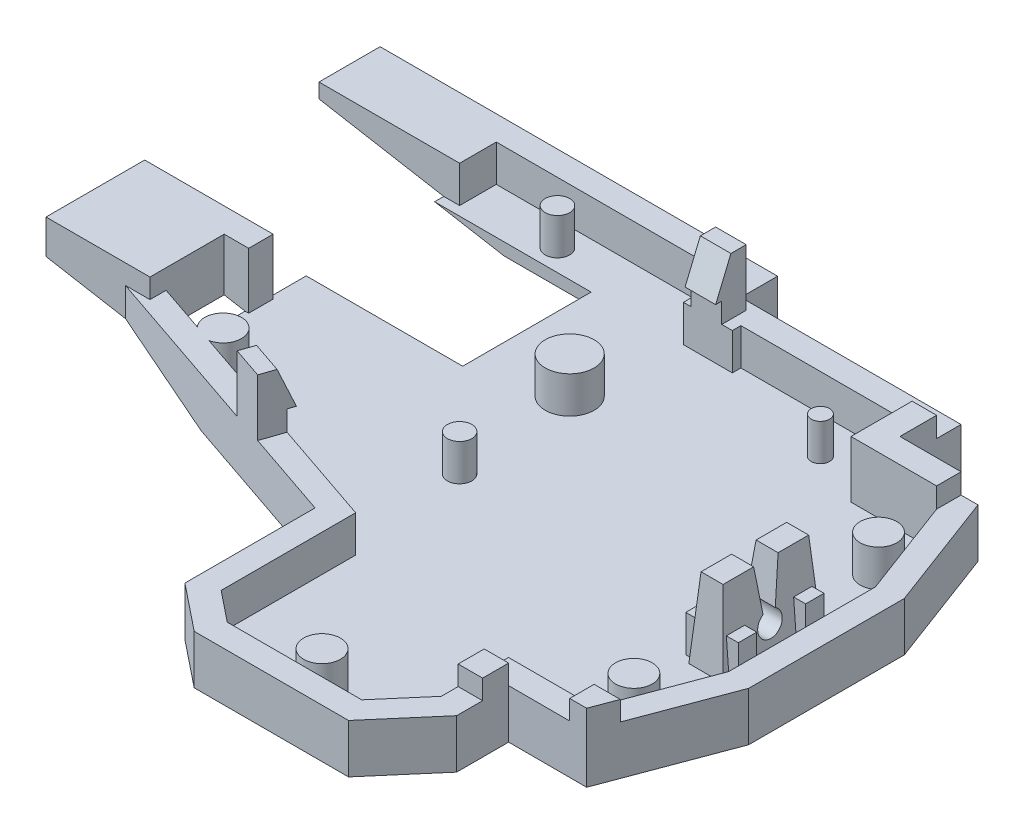
from build123d import *

# Parameters (mm, degrees)
SKETCH13_W           = 50
SKETCH13_H           = 45
BOSS_EXTRUDE4_DEPTH  = 1.6
SKETCH14_W           = 10
SKETCH14_H           = 8
CUT_EXTRUDE6_DEPTH   = 2.6
SKETCH15_W           = 18
SKETCH15_H           = 3
CUT_EXTRUDE7_DEPTH   = 2.6
SKETCH16_W           = 4
SKETCH16_H           = 0.7
CUT_EXTRUDE8_DEPTH   = 2.6
CUT_EXTRUDE9_DEPTH   = 2.6
SKETCH18_W           = 21.109590793
SKETCH18_H           = 22.840524871
CUT_EXTRUDE10_DEPTH  = 2.6
CUT_EXTRUDE11_DEPTH  = 2.6
SKETCH22_W           = 2
SKETCH22_H           = 3
CUT_EXTRUDE12_DEPTH  = 2.6
CUT_EXTRUDE13_DEPTH  = 2.6
CUT_EXTRUDE14_DEPTH  = 2.6
SKETCH25_W           = 2.8
SKETCH25_H           = 8
CUT_EXTRUDE15_DEPTH  = 2.6
BOSS_EXTRUDE6_DEPTH  = 6
SKETCH30_W           = 2.8
SKETCH30_H           = 8
BOSS_EXTRUDE7_DEPTH  = 3.5
CUT_EXTRUDE16_DEPTH  = 4.6
SKETCH32_W           = 2.8
SKETCH32_H           = 8
BOSS_EXTRUDE8_DEPTH  = 4.6
CUT_EXTRUDE18_DEPTH  = 4.6
SKETCH37_R           = 1
CUT_EXTRUDE19_DEPTH  = 4.6
CUT_EXTRUDE20_DEPTH  = 4.6
CUT_EXTRUDE21_START  = 6
CUT_EXTRUDE21_DEPTH  = 20.059798
BOSS_EXTRUDE9_DEPTH  = 4.6
SKETCH44_W           = 4.3
SKETCH44_H           = 1.5
BOSS_EXTRUDE11_DEPTH = 3
SKETCH45_R           = 1.5
SKETCH45_R_2         = 1
SKETCH45_R_3         = 1.999622229
SKETCH45_R_4         = 1.503341979
SKETCH45_R_5         = 0.75
BOSS_EXTRUDE12_DEPTH = 3
SKETCH46_W           = 2.5
SKETCH46_H           = 2
SKETCH46_W_2         = 2
BOSS_EXTRUDE13_DEPTH = 1.65
SKETCH47_W           = 3
SKETCH47_H           = 3
BOSS_EXTRUDE14_DEPTH = 3
SKETCH48_W           = 2
SKETCH48_H           = 16.336241737
CUT_EXTRUDE22_DEPTH  = 3
SKETCH49_W           = 21.336241737
SKETCH49_H           = 3
BOSS_EXTRUDE15_DEPTH = 13
SKETCH50_W           = 67
SKETCH50_H           = 49
BOSS_EXTRUDE16_DEPTH = 3
SKETCH51_W           = 5
SKETCH51_H           = 11
BOSS_EXTRUDE17_DEPTH = 15.6
CUT_EXTRUDE23_DEPTH  = 1.65
SKETCH53_W           = 2
SKETCH53_H           = 2.129349353
BOSS_EXTRUDE18_DEPTH = 1.6
SKETCH55_W           = 2.5
SKETCH55_H           = 2.5
BOSS_EXTRUDE20_DEPTH = 3
CUT_EXTRUDE24_DEPTH  = 3
SKETCH58_W           = 20
SKETCH58_H           = 10.5
SKETCH58_W_2         = 2
SKETCH58_H_2         = 2
CUT_EXTRUDE29_DEPTH  = 1
BOSS_EXTRUDE21_DEPTH = 3
BOSS_EXTRUDE22_REACH = 41.731
SKETCH61_W           = 2.5
SKETCH61_H           = 1.65
CUT_EXTRUDE30_DEPTH  = 3
CUT_EXTRUDE31_REACH  = 43.731
SKETCH64_W           = 2.551500858
SKETCH64_H           = 4.310788114
CUT_EXTRUDE32_DEPTH  = 4.65
SKETCH65_W           = 2
SKETCH65_H           = 2
BOSS_EXTRUDE23_DEPTH = 4
SKETCH66_W           = 2
SKETCH66_H           = 2
BOSS_EXTRUDE24_DEPTH = 1.6
SKETCH67_W           = 2.5
SKETCH67_H           = 2
BOSS_EXTRUDE25_DEPTH = 3
CUT_EXTRUDE33_DEPTH  = 3
BOSS_EXTRUDE26_DEPTH = 1.65
SKETCH70_W           = 5.055009343
SKETCH70_H           = 5.560438358
CUT_EXTRUDE34_DEPTH  = 3
BOSS_EXTRUDE27_DEPTH = 3
CUT_EXTRUDE35_DEPTH  = 3
BOSS_EXTRUDE28_REACH = 39.863
CUT_EXTRUDE36_DEPTH  = 3
FILLET8_R            = 1
SKETCH76_W           = 7
SKETCH76_H           = 14.5
BOSS_EXTRUDE29_DEPTH = 14.5
BOSS_EXTRUDE30_DEPTH = 2
CUT_EXTRUDE37_DEPTH  = 2
BOSS_EXTRUDE31_DEPTH = 2.684479
SKETCH85_W           = 30.566158209
SKETCH85_H           = 1.725230041
BOSS_EXTRUDE33_DEPTH = 3
BOSS_EXTRUDE34_DEPTH = 3
BOSS_EXTRUDE35_DEPTH = 3
SKETCH88_W           = 27.09375
SKETCH88_H           = 14.5
BOSS_EXTRUDE36_DEPTH = 1.6
SKETCH90_W           = 7
SKETCH90_H           = 14.5
BOSS_EXTRUDE37_DEPTH = 1.6
SKETCH93_W           = 5
SKETCH93_H           = 11
BOSS_EXTRUDE38_DEPTH = 0.5
SKETCH94_W           = 8.605758832
SKETCH94_H           = 2
BOSS_EXTRUDE39_DEPTH = 15.6
SKETCH96_W           = 8.605758832
SKETCH96_H           = 2
BOSS_EXTRUDE40_DEPTH = 0.5
SKETCH97_W           = 2
SKETCH97_H           = 49
BOSS_EXTRUDE41_DEPTH = 19.1
SKETCH98_W           = 69
SKETCH98_H           = 2
BOSS_EXTRUDE42_DEPTH = 19.1
SKETCH99_W           = 2
SKETCH99_H           = 3
BOSS_EXTRUDE43_DEPTH = 2.087376
SKETCH100_W          = 2
SKETCH100_H          = 51
BOSS_EXTRUDE45_DEPTH = 19.1
SKETCH101_W          = 71
SKETCH101_H          = 2
BOSS_EXTRUDE46_DEPTH = 19.1
BOSS_EXTRUDE47_DEPTH = 16.1
BOSS_EXTRUDE48_DEPTH = 16.1
FILLET9_R            = 2
SKETCH105_OUTSIDE_W  = 91.128
SKETCH105_OUTSIDE_H  = 73.128
CUT_EXTRUDE38_DEPTH  = 3
SKETCH106_W          = 77.0560479
SKETCH106_H          = 58.523580684
CUT_EXTRUDE39_DEPTH  = 20.1
SKETCH107_W          = 13.37564089
SKETCH107_H          = 6.179627402
CUT_EXTRUDE40_DEPTH  = 11.5
CUT_EXTRUDE41_DEPTH  = 4
SKETCH114_W          = 66.336817547
SKETCH114_H          = 51.668552302
CUT_EXTRUDE42_DEPTH  = 2
BOSS_EXTRUDE49_DEPTH = 6.5
SKETCH116_W          = 0.628599621
SKETCH116_H          = 10.5
CUT_EXTRUDE43_DEPTH  = 6.5
SKETCH117_W          = 8.5
SKETCH117_H          = 8.070282703
BOSS_EXTRUDE50_DEPTH = 1.6
SKETCH122_W          = 65.07142159
SKETCH122_H          = 113.694314663
CUT_EXTRUDE44_DEPTH  = 3.757461708


with BuildPart() as part:
    # Sketch13 → Boss-Extrude4 (new body)
    with BuildSketch(Plane(origin=(0, 0, 0), x_dir=(1, 0, 0), z_dir=(0, 1, 0))):
        with Locations((25, -22.5)):
            Rectangle(SKETCH13_W, SKETCH13_H)
    extrude(amount=BOSS_EXTRUDE4_DEPTH)

    # Sketch14 → Cut-Extrude6 (cut, through all)
    with BuildSketch(Plane(origin=(0, 1.6, 0), x_dir=(1, 0, 0), z_dir=(0, 1, 0))):
        with Locations((45, -4)):
            Rectangle(SKETCH14_W, SKETCH14_H)
    extrude(amount=-CUT_EXTRUDE6_DEPTH, mode=Mode.SUBTRACT)

    # Sketch15 → Cut-Extrude7 (cut, through all)
    with BuildSketch(Plane(origin=(0, 1.6, 0), x_dir=(1, 0, 0), z_dir=(0, 1, 0))):
        with Locations((31, -1.5)):
            Rectangle(SKETCH15_W, SKETCH15_H)
    extrude(amount=-CUT_EXTRUDE7_DEPTH, mode=Mode.SUBTRACT)

    # Sketch16 → Cut-Extrude8 (cut, through all)
    with BuildSketch(Plane(origin=(0, 1.6, 0), x_dir=(1, 0, 0), z_dir=(0, 1, 0))):
        with Locations((24, -3.35)):
            Rectangle(SKETCH16_W, SKETCH16_H)
    extrude(amount=-CUT_EXTRUDE8_DEPTH, mode=Mode.SUBTRACT)

    # Sketch17 → Cut-Extrude9 (cut, through all)
    with BuildSketch(Plane(origin=(0, 1.6, 0), x_dir=(1, 0, 0), z_dir=(0, 1, 0))):
        Polygon((47, -8), (50, -16), (65.881056194, -16), (65.881056194, 17.957346821), (47, 17.957346821), align=None)
    extrude(amount=-CUT_EXTRUDE9_DEPTH, mode=Mode.SUBTRACT)

    # Sketch18 → Cut-Extrude10 (cut, through all)
    with BuildSketch(Plane(origin=(0, 1.6, 0), x_dir=(1, 0, 0), z_dir=(0, 1, 0))):
        with Locations((50.554795396, -47.420262436)):
            Rectangle(SKETCH18_W, SKETCH18_H)
    extrude(amount=-CUT_EXTRUDE10_DEPTH, mode=Mode.SUBTRACT)

    # Sketch21 → Cut-Extrude11 (cut, through all)
    with BuildSketch(Plane(origin=(0, 1.6, 0), x_dir=(1, 0, 0), z_dir=(0, 1, 0))):
        Polygon((50, -28), (47, -36), (47, -49.297594069), (75.196774358, -49.297594069), (75.196774358, -28), align=None)
    extrude(amount=-CUT_EXTRUDE11_DEPTH, mode=Mode.SUBTRACT)

    # Sketch22 → Cut-Extrude12 (cut, through all)
    with BuildSketch(Plane(origin=(0, 1.6, 0), x_dir=(1, 0, 0), z_dir=(0, 1, 0))):
        with Locations((1, -20.836241737)):
            Rectangle(SKETCH22_W, SKETCH22_H)
    extrude(amount=-CUT_EXTRUDE12_DEPTH, mode=Mode.SUBTRACT)

    # Sketch23 → Cut-Extrude13 (cut, through all)
    with BuildSketch(Plane(origin=(0, 1.6, 0), x_dir=(1, 0, 0), z_dir=(0, 1, 0))):
        Polygon((23.5, -45), (23.5, -32), (0, -26.336241737), (-30.2261683, -26.336241737), (-30.2261683, -63.188280898), (23.5, -63.188280898), align=None)
    extrude(amount=-CUT_EXTRUDE13_DEPTH, mode=Mode.SUBTRACT)

    # Sketch24 → Cut-Extrude14 (cut, through all)
    with BuildSketch(Plane(origin=(0, 1.6, 0), x_dir=(1, 0, 0), z_dir=(0, 1, 0))):
        Polygon((23.5, -43), (7.491129632, -43), (7.491129632, -69.550234766), (44.754002286, -69.550234766), (44.754002286, -41.5), (40, -41.5), (37, -45), (26, -45), align=None)
    extrude(amount=-CUT_EXTRUDE14_DEPTH, mode=Mode.SUBTRACT)

    # Sketch25 → Cut-Extrude15 (cut, through all)
    with BuildSketch(Plane(origin=(0, 1.6, 0), x_dir=(1, 0, 0), z_dir=(0, 1, 0))):
        with Locations((46.200745069, -22.059797812)):
            Rectangle(SKETCH25_W, SKETCH25_H)
    extrude(amount=-CUT_EXTRUDE15_DEPTH, mode=Mode.SUBTRACT)

    # Sketch28 → Boss-Extrude6 (add)
    with BuildSketch(Plane.XZ):
        Polygon((42, 38), (42, 42.239848152), (37.919869845, 47), (25.298437881, 47), (21.5, 43.961249695), (21.5, 33.575244456), (-2, 27.911486193), (-2, -2), (24, -2), (24, 1), (42, 1), (42, 6), (48.386000936, 6), (52, 15.637330836), (52, 28.362669164), (48.386000936, 38), align=None)
    extrude(amount=BOSS_EXTRUDE6_DEPTH)

    # Sketch30 → Boss-Extrude7 (add)
    with BuildSketch(Plane(origin=(0, 0, 0), x_dir=(1, 0, 0), z_dir=(0, 1, 0))):
        with Locations((46.200745069, -22.059797812)):
            Rectangle(SKETCH30_W, SKETCH30_H)
    extrude(amount=BOSS_EXTRUDE7_DEPTH)

    # Sketch31 → Cut-Extrude16 (cut)
    with BuildSketch(Plane(origin=(0, 1.6, 0), x_dir=(1, 0, 0), z_dir=(0, 1, 0))):
        Polygon((37, -45), (40, -41.5), (40, -36), (47, -36), (50, -28), (50, -16), (47, -8), (40, -8), (40, -3), (26, -3), (26, -3.7), (22, -3.7), (22, 0), (0, 0), (0, -19.336241737), (2, -19.336241737), (2, -22.336241737), (0, -22.336241737), (0, -26.336241737), (23.5, -32), (23.5, -43), (26, -45), align=None)
    extrude(amount=-CUT_EXTRUDE16_DEPTH, mode=Mode.SUBTRACT)

    # Sketch32 → Boss-Extrude8 (add)
    with BuildSketch(Plane.XZ.offset(-1.6)):
        with Locations((46.200745069, 22.059797812)):
            Rectangle(SKETCH32_W, SKETCH32_H)
    extrude(amount=BOSS_EXTRUDE8_DEPTH)

    # Sketch35 → Cut-Extrude18 (cut)
    with BuildSketch(Plane(origin=(47.600745069, 0, 0), x_dir=(0, 0, -1), z_dir=(1, 0, 0))):
        Polygon((-22.059797812, 0), (-21.559797812, 0), (-21.059797812, 3.5), (-21.297672794, 5.165124873), (-23.257672794, 4.885124873), (-23.059797812, 3.5), (-22.559797812, 0), align=None)
    extrude(amount=-CUT_EXTRUDE18_DEPTH, mode=Mode.SUBTRACT)

    # Sketch37 → Cut-Extrude19 (cut)
    with BuildSketch(Plane(origin=(47.600745069, 0, 0), x_dir=(0, 0, -1), z_dir=(1, 0, 0))):
        with Locations((-22.059797812, -0.866025404)):
            Circle(SKETCH37_R)
    extrude(amount=-CUT_EXTRUDE19_DEPTH, mode=Mode.SUBTRACT)

    # Sketch39 → Cut-Extrude20 (cut)
    with BuildSketch(Plane.ZY.offset(-44.800745069)):
        Polygon((25.559797812, 3.5), (26.059797812, -3), (27.906381513, -2.8579551), (27.406381513, 3.6420449), align=None)
        Polygon((18.559797812, 3.5), (18.059797812, -3), (15.957253652, -2.838265834), (16.455739093, 3.6420449), align=None)
    extrude(amount=-CUT_EXTRUDE20_DEPTH, mode=Mode.SUBTRACT)

    # Sketch41 → Cut-Extrude21 (cut)
    with BuildSketch(Plane.XY.offset(CUT_EXTRUDE21_START)):
        Polygon((45.300745069, 3.5), (44.800745069, -3), (43.414957387, -2.893400947), (43.940591177, 3.939838325), align=None)
        Polygon((47.100745069, 3.5), (47.600745069, -3), (49.658968536, -2.841675118), (49.137313656, 3.939838325), align=None)
    extrude(amount=CUT_EXTRUDE21_DEPTH, mode=Mode.SUBTRACT)

    # Sketch43 → Boss-Extrude9 (add)
    with BuildSketch(Plane(origin=(0, 0, 0), x_dir=(1, 0, 0), z_dir=(0, 1, 0))):
        Polygon((47, -8), (50, -16), (51.170411472, -13.425094762), (48.386000936, -6), (42.818763345, -6), (42.818763345, -8), align=None)
    extrude(amount=-BOSS_EXTRUDE9_DEPTH)

    # Sketch44 → Boss-Extrude11 (add)
    with BuildSketch(Plane(origin=(0, -3, 0), x_dir=(1, 0, 0), z_dir=(0, 1, 0))):
        with Locations((46.200745069, -19.309797812)):
            Rectangle(SKETCH44_W, SKETCH44_H)
        with Locations((46.200745069, -24.809797812)):
            Rectangle(SKETCH44_W, SKETCH44_H)
    extrude(amount=BOSS_EXTRUDE11_DEPTH)

    # Sketch45 → Boss-Extrude12 (add)
    with BuildSketch(Plane(origin=(0, -3, 0), x_dir=(1, 0, 0), z_dir=(0, 1, 0))):
        with Locations((46.25, -12)):
            Circle(SKETCH45_R)
        with Locations((46.25, -32)):
            Circle(SKETCH45_R)
        with Locations((22, -22)):
            Circle(SKETCH45_R_2)
        with Locations((21, -12)):
            Circle(SKETCH45_R_3)
        with Locations((31.75, -43)):
            Circle(SKETCH45_R_4)
        with Locations((35.5, -6)):
            Circle(SKETCH45_R_5)
        with Locations((10, -2)):
            Circle(SKETCH45_R_2)
        with Locations((5, -24.336241737)):
            Circle(SKETCH45_R)
    extrude(amount=BOSS_EXTRUDE12_DEPTH)

    # Sketch46 → Boss-Extrude13 (add)
    with BuildSketch(Plane(origin=(0, 0, 0), x_dir=(1, 0, 0), z_dir=(0, 1, 0))):
        Polygon((14.137316506, -29.743490383), (16.567726059, -30.329245795), (16.099121729, -32.273573438), (13.668712176, -31.687818026), align=None)
        with Locations((23.883625006, -2.7)):
            Rectangle(SKETCH46_W, SKETCH46_H)
        with Locations((1, -20.932723283)):
            Rectangle(SKETCH46_W_2, SKETCH46_H)
        Polygon((47, -36), (48.872658355, -36.702246883), (49.750466959, -34.361423939), (47.877808604, -33.659177056), align=None)
        Polygon((40, -3), (40, -8), (47, -8), (47, -6), (42, -6), (42, -3), align=None)
    extrude(amount=BOSS_EXTRUDE13_DEPTH)

    # Sketch47 → Boss-Extrude14 (add)
    with BuildSketch(Plane(origin=(0, 0, 0), x_dir=(1, 0, 0), z_dir=(0, 1, 0))):
        with Locations((1.5, -1.5)):
            Rectangle(SKETCH47_W, SKETCH47_H)
    extrude(amount=-BOSS_EXTRUDE14_DEPTH)

    # Sketch48 → Cut-Extrude22 (cut)
    with BuildSketch(Plane(origin=(0, 0, 0), x_dir=(1, 0, 0), z_dir=(0, 1, 0))):
        with Locations((-1, -11.168120869)):
            Rectangle(SKETCH48_W, SKETCH48_H)
    extrude(amount=-CUT_EXTRUDE22_DEPTH, mode=Mode.SUBTRACT)

    # Sketch49 → Boss-Extrude15 (add)
    with BuildSketch(Plane.ZY.offset(2)):
        with Locations((8.668120869, -4.5)):
            Rectangle(SKETCH49_W, SKETCH49_H)
    extrude(amount=BOSS_EXTRUDE15_DEPTH)

    # Sketch50 → Boss-Extrude16 (add)
    with BuildSketch(Plane.XZ.offset(6)):
        with Locations((18.5, 22.5)):
            Rectangle(SKETCH50_W, SKETCH50_H)
    extrude(amount=-BOSS_EXTRUDE16_DEPTH)

    # Sketch51 → Boss-Extrude17 (add)
    with BuildSketch(Plane(origin=(0, -3, 0), x_dir=(1, 0, 0), z_dir=(0, 1, 0))):
        with Locations((49.5, -41.5)):
            Rectangle(SKETCH51_W, SKETCH51_H)
    extrude(amount=BOSS_EXTRUDE17_DEPTH)

    # Sketch52 → Cut-Extrude23 (cut)
    with BuildSketch(Plane(origin=(0, 1.65, 0), x_dir=(1, 0, 0), z_dir=(0, 1, 0))):
        Polygon((47.877808604, -33.659177056), (47, -36), (49.136000936, -36), (49.750466959, -34.361423939), align=None)
    extrude(amount=-CUT_EXTRUDE23_DEPTH, mode=Mode.SUBTRACT)

    # Sketch53 → Boss-Extrude18 (add)
    with BuildSketch(Plane(origin=(0, 0, 0), x_dir=(1, 0, 0), z_dir=(0, 1, 0))):
        with Locations((41, -39.055249399)):
            Rectangle(SKETCH53_W, SKETCH53_H)
    extrude(amount=BOSS_EXTRUDE18_DEPTH)

    # Sketch55 → Boss-Extrude20 (add)
    with BuildSketch(Plane(origin=(0, 1.65, 0), x_dir=(1, 0, 0), z_dir=(0, 1, 0))):
        with Locations((23.883625006, -2.95)):
            Rectangle(SKETCH55_W, SKETCH55_H)
    extrude(amount=BOSS_EXTRUDE20_DEPTH)

    # Sketch56 → Cut-Extrude24 (cut)
    with BuildSketch(Plane(origin=(25.133625006, 0, 0), x_dir=(0, 0, -1), z_dir=(1, 0, 0))):
        Polygon((-4.2, 1.65), (-2.95, 4.65), (-2.95, 7.68728323), (-6.59715338, 7.68728323), (-6.59715338, 1.641289328), align=None)
    extrude(amount=-CUT_EXTRUDE24_DEPTH, mode=Mode.SUBTRACT)

    # Sketch58 → Cut-Extrude29 (cut)
    with BuildSketch(Plane(origin=(0, -3, 0), x_dir=(1, 0, 0), z_dir=(0, 1, 0))):
        with Locations((4.5, -9)):
            Rectangle(SKETCH58_W, SKETCH58_H)
        with Locations((1, -18.248866233)):
            Rectangle(SKETCH58_W_2, SKETCH58_H_2)
    extrude(amount=-CUT_EXTRUDE29_DEPTH, mode=Mode.SUBTRACT)

    # Sketch60 → Boss-Extrude21 (add)
    with BuildSketch(Plane(origin=(0, -3, 0), x_dir=(1, 0, 0), z_dir=(0, 1, 0))):
        Polygon((0, -24), (23.5, -32), (0, -26.336241737), align=None)
    extrude(amount=BOSS_EXTRUDE21_DEPTH)

    # Boss-Extrude22: up to this face of the body (flat: up to its plane)
    boss_extrude22_end = Plane(part.part.faces().sort_by_distance((14.401539714, -1.5, 28.902651818))[0])
    # Sketch61 → Boss-Extrude22 (add, up to the picked face)
    with BuildSketch(Plane(origin=(-5.998871461, 0, 24.890447788), x_dir=(-0.972163821, 0, -0.234302165), z_dir=(0.234302165, 0, -0.972163821)), mode=Mode.PRIVATE) as boss_extrude22_sk1:
        with Locations((-21.962751827, 0.825)):
            Rectangle(SKETCH61_W, SKETCH61_H)
    boss_extrude22_tool1 = split(extrude(boss_extrude22_sk1.sketch, amount=BOSS_EXTRUDE22_REACH, mode=Mode.PRIVATE), bisect_by=boss_extrude22_end, keep=Keep.BOTH, mode=Mode.PRIVATE)
    add(boss_extrude22_tool1.solids().sort_by_distance((15.352521, 0.825, 30.036368))[0])

    # Sketch62 → Cut-Extrude30 (cut)
    with BuildSketch(Plane(origin=(0, 0, 0), x_dir=(1, 0, 0), z_dir=(0, 1, 0))):
        Polygon((0, -26), (-0.545193502, -28.262110548), (-9.931116312, -26), (-9.25988925, -22.847697277), align=None)
    extrude(amount=-CUT_EXTRUDE30_DEPTH, mode=Mode.SUBTRACT)

    # Cut-Extrude31: up to this face of the body (flat: up to its plane)
    cut_extrude31_end = Plane(part.part.faces().sort_by_distance((-1, -1.5, 25.659574468))[0])
    # Sketch63 → Cut-Extrude31 (cut, up to the picked face)
    with BuildSketch(Plane(origin=(-6.46747579, 0, 26.834775431), x_dir=(0.972163821, 0, 0.234302165), z_dir=(-0.234302165, 0, 0.972163821)), mode=Mode.PRIVATE) as cut_extrude31_sk1:
        Polygon((20.712751827, 0), (6.091856288, 0), (6.091856288, -3), (28.768274623, -3), (28.768274623, 0), (23.212751827, 0), (23.212751827, 1.65), (20.712751827, 1.65), align=None)
    cut_extrude31_tool1 = split(extrude(cut_extrude31_sk1.sketch, amount=-CUT_EXTRUDE31_REACH, mode=Mode.PRIVATE), bisect_by=cut_extrude31_end, keep=Keep.BOTH, mode=Mode.PRIVATE)
    add(cut_extrude31_tool1.solids().sort_by_distance((10.72932, -1.367082, 30.979392))[0], mode=Mode.SUBTRACT)

    # Sketch64 → Cut-Extrude32 (cut)
    with BuildSketch(Plane(origin=(0, 1.65, 0), x_dir=(1, 0, 0), z_dir=(0, 1, 0))):
        with Locations((1.275750429, -20.806985271)):
            Rectangle(SKETCH64_W, SKETCH64_H)
    extrude(amount=-CUT_EXTRUDE32_DEPTH, mode=Mode.SUBTRACT)

    # Sketch65 → Boss-Extrude23 (add)
    with BuildSketch(Plane(origin=(0, -4, 0), x_dir=(1, 0, 0), z_dir=(0, 1, 0))):
        with Locations((1, -18.248866233)):
            Rectangle(SKETCH65_W, SKETCH65_H)
    extrude(amount=BOSS_EXTRUDE23_DEPTH)

    # Sketch66 → Boss-Extrude24 (add)
    with BuildSketch(Plane(origin=(0, 0, 0), x_dir=(1, 0, 0), z_dir=(0, 1, 0))):
        with Locations((1, -18.248866233)):
            Rectangle(SKETCH66_W, SKETCH66_H)
    extrude(amount=BOSS_EXTRUDE24_DEPTH)

    # Sketch67 → Boss-Extrude25 (add)
    with BuildSketch(Plane(origin=(0, 1.6, 0), x_dir=(1, 0, 0), z_dir=(0, 1, 0))):
        with Locations((1.25, -18.248866233)):
            Rectangle(SKETCH67_W, SKETCH67_H)
    extrude(amount=BOSS_EXTRUDE25_DEPTH)

    # Sketch68 → Cut-Extrude33 (cut)
    with BuildSketch(Plane(origin=(0, 0, 17.248866233), x_dir=(-1, 0, 0), z_dir=(0, 0, -1))):
        Polygon((-2.5, 1.6), (-1.25, 4.6), (-1.25, 6.77486743), (-4.497451498, 6.77486743), (-4.497451498, 1.567063174), align=None)
    extrude(amount=-CUT_EXTRUDE33_DEPTH, mode=Mode.SUBTRACT)

    # Sketch69 → Boss-Extrude26 (add)
    with BuildSketch(Plane(origin=(0, 1.65, 0), x_dir=(1, 0, 0), z_dir=(0, 1, 0))):
        Polygon((14.344636536, -28.883280523), (16.885898362, -29.748390932), (16.275756374, -31.540683021), (13.734494548, -30.675572612), align=None)
    extrude(amount=-BOSS_EXTRUDE26_DEPTH)

    # Sketch70 → Cut-Extrude34 (cut)
    with BuildSketch(Plane.XY.offset(19.248866233)):
        with Locations((-0.027504672, 4.380219179)):
            Rectangle(SKETCH70_W, SKETCH70_H)
    extrude(amount=-CUT_EXTRUDE34_DEPTH, mode=Mode.SUBTRACT)

    # Sketch71 → Boss-Extrude27 (add)
    with BuildSketch(Plane(origin=(0, 1.65, 0), x_dir=(1, 0, 0), z_dir=(0, 1, 0))):
        Polygon((16.275756374, -31.540683021), (17.081415869, -29.174058256), (14.559846057, -28.298525857), (13.734494548, -30.675572612), align=None)
    extrude(amount=BOSS_EXTRUDE27_DEPTH)

    # Sketch72 → Cut-Extrude35 (cut)
    with BuildSketch(Plane(origin=(24.207602216, 0, 8.240885861), x_dir=(0.322263798, 0, -0.946649906), z_dir=(0.946649906, 0, 0.322263798))):
        Polygon((-22.112897557, 1.65), (-23.362897557, 4.65), (-23.362897557, 7.694800469), (-20.734818485, 7.694800469), (-20.734818485, 1.65), align=None)
    extrude(amount=-CUT_EXTRUDE35_DEPTH, mode=Mode.SUBTRACT)

    # Boss-Extrude28: up to this face of the body (flat: up to its plane)
    boss_extrude28_end = Plane(part.part.faces().sort_by_distance((14.039565542, 0.825, 29.779426567))[0])
    # Sketch73 → Boss-Extrude28 (add, up to the picked face)
    with BuildSketch(Plane(origin=(21.761963317, 0, 7.556127878), x_dir=(-0.328007452, 0, 0.944675136), z_dir=(-0.944675136, 0, -0.328007452)), mode=Mode.PRIVATE) as boss_extrude28_sk1:
        Polygon((24.473434161, 4.65), (23.223411105, 4.65), (21.973388049, 1.65), (22.580099427, 1.65), (24.473434161, 1.65), align=None)
    boss_extrude28_tool1 = split(extrude(boss_extrude28_sk1.sketch, amount=BOSS_EXTRUDE28_REACH, mode=Mode.PRIVATE), bisect_by=boss_extrude28_end, keep=Keep.BOTH, mode=Mode.PRIVATE)
    add(boss_extrude28_tool1.solids().sort_by_distance((14.053397, 2.983333, 29.757122))[0])

    # Sketch74 → Cut-Extrude36 (cut)
    with BuildSketch(Plane(origin=(0, -4, 0), x_dir=(1, 0, 0), z_dir=(0, 1, 0))):
        with BuildLine():
            Line((6.419171569, -6.169171569), (2.580828431, -6.169171569))
            ThreePointArc((2.580828431, -6.169171569), (-0.25, -9), (2.580828431, -11.830828431))
            Line((2.580828431, -11.830828431), (6.419171569, -11.830828431))
            ThreePointArc((6.419171569, -11.830828431), (9.25, -9), (6.419171569, -6.169171569))
        make_face()
    extrude(amount=-CUT_EXTRUDE36_DEPTH, mode=Mode.SUBTRACT)

    # Fillet8
    fillet8_edges = [part.edges().sort_by_distance(p)[0] for p in [
        (-0.25, -6, 9),
        (4.5, -6, 6.169171569),
        (9.25, -6, 9),
        (4.5, -6, 11.830828431),
    ]]
    fillet(fillet8_edges, radius=FILLET8_R)

    # Sketch76 → Boss-Extrude29 (add)
    with BuildSketch(Plane(origin=(0, -3, 0), x_dir=(1, 0, 0), z_dir=(0, 1, 0))):
        with Locations((-11.5, -39.75)):
            Rectangle(SKETCH76_W, SKETCH76_H)
    extrude(amount=BOSS_EXTRUDE29_DEPTH)

    # Sketch79 → Boss-Extrude30 (add)
    with BuildSketch(Plane(origin=(21.66634039, 0, 7.375775452), x_dir=(-0.322263798, 0, 0.946649906), z_dir=(-0.946649906, 0, -0.322263798))):
        Polygon((22.719597745, 0), (24.612897557, 0), (24.612897557, 4.65), (23.362851444, 4.65), (22.112805332, 1.65), (22.719597745, 1.65), align=None)
    extrude(amount=BOSS_EXTRUDE30_DEPTH)

    # Sketch80 → Cut-Extrude37 (cut)
    with BuildSketch(Plane(origin=(24.207602216, 0, 8.240885861), x_dir=(0.322263798, 0, -0.946649906), z_dir=(0.946649906, 0, 0.322263798))):
        Polygon((-22.112897557, 1.65), (-23.362897557, 4.65), (-24.612897557, 4.65), (-24.612897557, 0), (-22.719597745, 0), (-22.719597745, 1.65), align=None)
    extrude(amount=-CUT_EXTRUDE37_DEPTH, mode=Mode.SUBTRACT)

    # Sketch83 → Boss-Extrude31 (add)
    with BuildSketch(Plane(origin=(19.773040578, 0, 6.731247856), x_dir=(-0.322263798, 0, 0.946649906), z_dir=(-0.946649906, 0, -0.322263798))):
        Polygon((22.719597745, 1.65), (22.719597745, 0), (24.612897557, 0), (24.612897557, 4.65), (23.362851444, 4.65), (22.112805332, 1.65), align=None)
    extrude(amount=-BOSS_EXTRUDE31_DEPTH)

    # Sketch85 → Boss-Extrude33 (add)
    with BuildSketch(Plane(origin=(0, -3, 0), x_dir=(1, 0, 0), z_dir=(0, 1, 0))):
        with Locations((7.283079105, -33.362615021)):
            Rectangle(SKETCH85_W, SKETCH85_H)
    extrude(amount=BOSS_EXTRUDE33_DEPTH)

    # Sketch86 → Boss-Extrude34 (add)
    with BuildSketch(Plane(origin=(0, -3, 0), x_dir=(1, 0, 0), z_dir=(0, 1, 0))):
        Polygon((21.5, -43.961249695), (21.5, -34.225230041), (-8, -34.225230041), (-8, -47), (25.298437881, -47), align=None)
    extrude(amount=BOSS_EXTRUDE34_DEPTH)

    # Sketch87 → Boss-Extrude35 (add)
    with BuildSketch(Plane(origin=(0, -3, 0), x_dir=(1, 0, 0), z_dir=(0, 1, 0))):
        Polygon((37.919869845, -47), (47, -47), (47, -38), (42, -38), (42, -42.239848152), align=None)
    extrude(amount=BOSS_EXTRUDE35_DEPTH)

    # Sketch88 → Boss-Extrude36 (add)
    with BuildSketch(Plane(origin=(0, 0, 0), x_dir=(1, 0, 0), z_dir=(0, 1, 0))):
        with Locations((5.546875, -39.75)):
            Rectangle(SKETCH88_W, SKETCH88_H)
    extrude(amount=BOSS_EXTRUDE36_DEPTH)

    # Sketch90 → Boss-Extrude37 (add)
    with BuildSketch(Plane(origin=(0, 11.5, 0), x_dir=(1, 0, 0), z_dir=(0, 1, 0))):
        with Locations((-11.5, -39.75)):
            Rectangle(SKETCH90_W, SKETCH90_H)
    extrude(amount=BOSS_EXTRUDE37_DEPTH)

    # Sketch93 → Boss-Extrude38 (add)
    with BuildSketch(Plane(origin=(0, 12.6, 0), x_dir=(1, 0, 0), z_dir=(0, 1, 0))):
        with Locations((49.5, -41.5)):
            Rectangle(SKETCH93_W, SKETCH93_H)
    extrude(amount=BOSS_EXTRUDE38_DEPTH)

    # Sketch94 → Boss-Extrude39 (add)
    with BuildSketch(Plane(origin=(0, -3, 0), x_dir=(1, 0, 0), z_dir=(0, 1, 0))):
        with Locations((5.421445221, -31.5)):
            Rectangle(SKETCH94_W, SKETCH94_H)
    extrude(amount=BOSS_EXTRUDE39_DEPTH)

    # Sketch96 → Boss-Extrude40 (add)
    with BuildSketch(Plane(origin=(0, 12.6, 0), x_dir=(1, 0, 0), z_dir=(0, 1, 0))):
        with Locations((5.421445221, -31.5)):
            Rectangle(SKETCH96_W, SKETCH96_H)
    extrude(amount=BOSS_EXTRUDE40_DEPTH)

    # Sketch97 → Boss-Extrude41 (add)
    with BuildSketch(Plane.XZ.offset(6)):
        with Locations((-16, 22.5)):
            Rectangle(SKETCH97_W, SKETCH97_H)
    extrude(amount=-BOSS_EXTRUDE41_DEPTH)

    # Sketch98 → Boss-Extrude42 (add)
    with BuildSketch(Plane.XZ.offset(6)):
        with Locations((17.5, 48)):
            Rectangle(SKETCH98_W, SKETCH98_H)
    extrude(amount=-BOSS_EXTRUDE42_DEPTH)

    # Sketch99 → Boss-Extrude43 (add)
    with BuildSketch(Plane(origin=(0, 0, 19.336241737), x_dir=(-1, 0, 0), z_dir=(0, 0, -1))):
        with Locations((1, -1.5)):
            Rectangle(SKETCH99_W, SKETCH99_H)
    extrude(amount=BOSS_EXTRUDE43_DEPTH)

    # Sketch100 → Boss-Extrude45 (add)
    with BuildSketch(Plane.XZ.offset(6)):
        with Locations((53, 23.5)):
            Rectangle(SKETCH100_W, SKETCH100_H)
    extrude(amount=-BOSS_EXTRUDE45_DEPTH)

    # Sketch101 → Boss-Extrude46 (add)
    with BuildSketch(Plane.XZ.offset(6)):
        with Locations((18.5, -3)):
            Rectangle(SKETCH101_W, SKETCH101_H)
    extrude(amount=-BOSS_EXTRUDE46_DEPTH)

    # Sketch102 → Boss-Extrude47 (add)
    with BuildSketch(Plane(origin=(0, -3, 0), x_dir=(1, 0, 0), z_dir=(0, 1, 0))):
        with BuildLine():
            Line((50, 2), (50, 2.836676417))
            Line((50, 2.836676417), (52.928518438, 2.836676417))
            Line((52.928518438, 2.836676417), (52.928518438, 0))
            Line((52.928518438, 0), (52, 0))
            ThreePointArc((52, 0), (51.414213562, 1.414213562), (50, 2))
        make_face()
    extrude(amount=BOSS_EXTRUDE47_DEPTH)

    # Sketch103 → Boss-Extrude48 (add)
    with BuildSketch(Plane(origin=(0, -3, 0), x_dir=(1, 0, 0), z_dir=(0, 1, 0))):
        with BuildLine():
            Line((-13, 2), (-13, 3.319267165))
            Line((-13, 3.319267165), (-16.315139414, 3.319267165))
            Line((-16.315139414, 3.319267165), (-16.315139414, 0))
            Line((-16.315139414, 0), (-15, 0))
            ThreePointArc((-15, 0), (-14.414213562, 1.414213562), (-13, 2))
        make_face()
    extrude(amount=BOSS_EXTRUDE48_DEPTH)

    # Fillet9
    fillet9_edges = [part.edges().sort_by_distance(p)[0] for p in [
        (-17, -6, 22.5),
        (18.5, -6, 49),
        (-17, 3.55, 49),
        (54, -6, 22.5),
        (54, 3.55, 49),
        (18.5, -6, -4),
        (-17, 3.55, -4),
        (54, 3.55, -4),
    ]]
    fillet(fillet9_edges, radius=FILLET9_R)

    # Sketch105 outside → Cut-Extrude38 (cut)
    with BuildSketch(Plane(origin=(0, 13.1, 0), x_dir=(1, 0, 0), z_dir=(0, 1, 0))):
        with Locations((18.5, -22.5)):
            Rectangle(SKETCH105_OUTSIDE_W, SKETCH105_OUTSIDE_H)
        with BuildLine():
            Line((-16, 2), (-16, -47))
            ThreePointArc((-16, -47), (-15.707106781, -47.707106781), (-15, -48))
            Line((-15, -48), (52, -48))
            ThreePointArc((52, -48), (52.707106781, -47.707106781), (53, -47))
            Line((53, -47), (53, 2))
            ThreePointArc((53, 2), (52.707106781, 2.707106781), (52, 3))
            Line((52, 3), (-15, 3))
            ThreePointArc((-15, 3), (-15.707106781, 2.707106781), (-16, 2))
        make_face(mode=Mode.SUBTRACT)
    extrude(amount=-CUT_EXTRUDE38_DEPTH, mode=Mode.SUBTRACT)

    # Sketch106 → Cut-Extrude39 (cut, through all)
    with BuildSketch(Plane.XZ.offset(6)):
        with Locations((17.692589571, 21.631481201)):
            Rectangle(SKETCH106_W, SKETCH106_H)
        Polygon((-2, -2), (24, -2), (24, 1), (42, 1), (42, 6), (48.386000936, 6), (52, 15.637330836), (52, 28.362669164), (49.136000936, 36), (48.386000936, 38), (42, 37.990574723), (42, 42.239848152), (37.919869845, 47), (25.298437881, 47), (21.5, 43.961249695), (21.5, 33.319148936), (-2, 25.319148936), (-2, 17.248866233), (-8.372079234, 17.248866233), (-8.372079234, 3), (-2, 3), align=None, mode=Mode.SUBTRACT)
    extrude(amount=-CUT_EXTRUDE39_DEPTH, mode=Mode.SUBTRACT)

    # Sketch107 → Cut-Extrude40 (cut)
    with BuildSketch(Plane(origin=(0, 13.1, 0), x_dir=(1, 0, 0), z_dir=(0, 1, 0))):
        with Locations((44.784273424, -38.274312053)):
            Rectangle(SKETCH107_W, SKETCH107_H)
    extrude(amount=-CUT_EXTRUDE40_DEPTH, mode=Mode.SUBTRACT)

    # Sketch113 → Cut-Extrude41 (cut, through all)
    with BuildSketch(Plane(origin=(0, -3, 0), x_dir=(1, 0, 0), z_dir=(0, 1, 0))):
        Polygon((-6.128599621, -3), (-6.128599621, -14.861393841), (-2, -14.861393841), (-2, -17.248866233), (-9.246534053, -26.452427809), (-13.814435406, -0.657200841), (-2.974123127, 6.68981616), (-3.537653946, 5.974095989), align=None)
    extrude(amount=-CUT_EXTRUDE41_DEPTH, mode=Mode.SUBTRACT)

    # Sketch114 → Cut-Extrude42 (cut)
    with BuildSketch(Plane.XZ.offset(6)):
        with Locations((24.645555619, 22.809022442)):
            Rectangle(SKETCH114_W, SKETCH114_H)
    extrude(amount=-CUT_EXTRUDE42_DEPTH, mode=Mode.SUBTRACT)

    # Sketch115 → Boss-Extrude49 (add)
    with BuildSketch(Plane.ZY.offset(2)):
        Polygon((14.861393841, -3), (14.861393841, -4), (25.319148936, -4), (25.319148936, 0), (17.248866233, 0), (17.248866233, -3), align=None)
        Polygon((-2, 0), (-2, -4), (3, -4), (3, -3), (3, 0), align=None)
    extrude(amount=BOSS_EXTRUDE49_DEPTH)

    # Sketch116 → Cut-Extrude43 (cut)
    with BuildSketch(Plane(origin=(0, -3, 0), x_dir=(1, 0, 0), z_dir=(0, 1, 0))):
        with Locations((-5.81429981, -9)):
            Rectangle(SKETCH116_W, SKETCH116_H)
    extrude(amount=-CUT_EXTRUDE43_DEPTH, mode=Mode.SUBTRACT)

    # Sketch117 → Boss-Extrude50 (add)
    with BuildSketch(Plane(origin=(0, 0, 0), x_dir=(1, 0, 0), z_dir=(0, 1, 0))):
        with Locations((-4.25, -21.284007585)):
            Rectangle(SKETCH117_W, SKETCH117_H)
    extrude(amount=BOSS_EXTRUDE50_DEPTH)

    # Sketch122 → Cut-Extrude44 (cut, through all)
    with BuildSketch(Plane(origin=(-0.461518448, -2.617401182, 0), x_dir=(0.984807753, -0.173648178, 0), z_dir=(0.173648178, 0.984807753, 0))):
        with Locations((7.932983667, 2.841117982)):
            Rectangle(SKETCH122_W, SKETCH122_H)
    extrude(amount=-CUT_EXTRUDE44_DEPTH, mode=Mode.SUBTRACT)


solid = part.part
